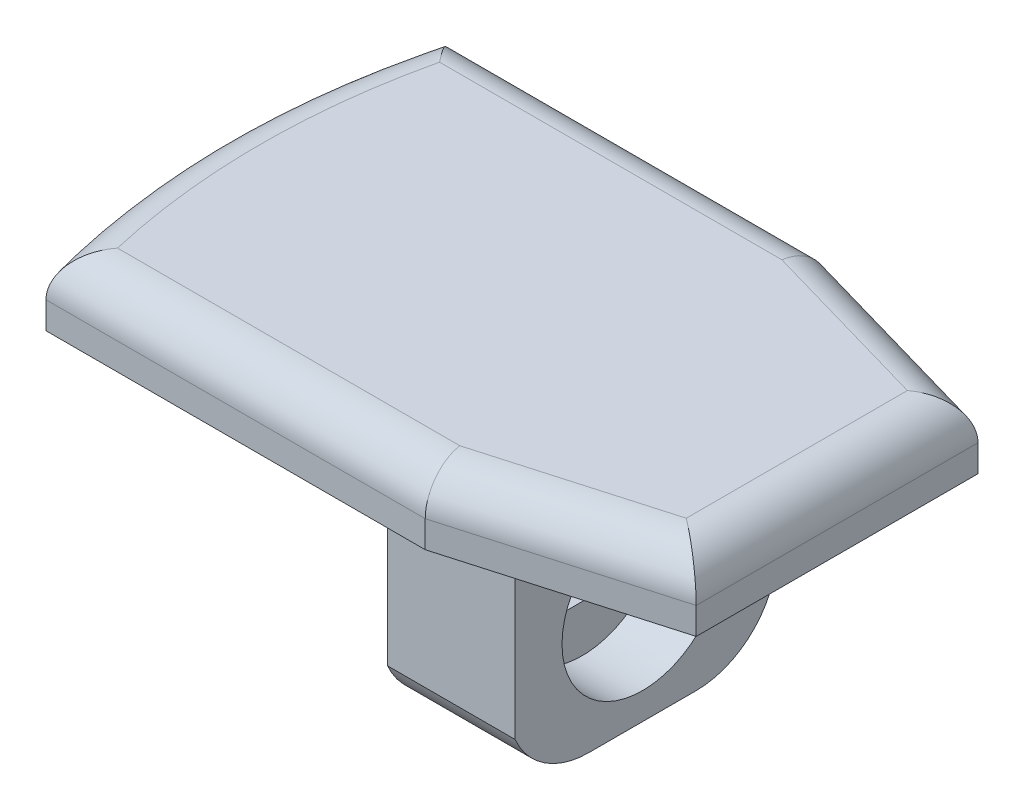
from build123d import *

# Parameters (mm, degrees)
BOSS_EXTRUDE1_DEPTH      = 2.5
BOSS_EXTRUDE2_DEPTH      = 1.5
BOSS_EXTRUDE2_DEPTH_BACK = 1.5
FILLET1_R                = 1.5
SKETCH5_W                = 5
SKETCH5_H                = 10
BOSS_EXTRUDE3_DEPTH      = 7.5
SKETCH6_R                = 3
CUT_EXTRUDE1_DEPTH       = 2.5
CUT_EXTRUDE2_DEPTH       = 2.5
FILLET2_R                = 3
CUT_EXTRUDE3_DEPTH       = 10


with BuildPart() as part:
    # Sketch1 → Boss-Extrude1 (new body)
    with BuildSketch(Plane(origin=(0, 0, 0), x_dir=(1, 0, 0), z_dir=(0, 1, 0))):
        with BuildLine():
            Line((-20.209371097, 50.622586501), (-32.257467167, 50.622586501))
            ThreePointArc((-32.257467167, 50.622586501), (-33.362688598, 43.122586501), (-32.257467167, 35.622586501))
            Line((-32.257467167, 35.622586501), (-20.209371097, 35.622586501))
            Line((-20.209371097, 35.622586501), (-12.362688598, 37.872586501))
            Line((-12.362688598, 37.872586501), (-12.362688598, 48.372586501))
            Line((-12.362688598, 48.372586501), (-20.209371097, 50.622586501))
        make_face()
        with BuildLine():
            Line((-32.257467167, 50.622586501), (-34.339530518, 50.622586501))
            ThreePointArc((-34.339530518, 50.622586501), (-35.362688598, 43.122586501), (-34.339530518, 35.622586501))
            Line((-34.339530518, 35.622586501), (-32.257467167, 35.622586501))
            ThreePointArc((-32.257467167, 35.622586501), (-33.362688598, 43.122586501), (-32.257467167, 50.622586501))
        make_face()
    extrude(amount=BOSS_EXTRUDE1_DEPTH)

    # Sketch4 → Boss-Extrude2 (add, two sides)
    with BuildSketch(Plane.XZ) as boss_extrude2_sk:
        with BuildLine():
            Line((-19.362688598, -38.122586501), (-32.877390242, -38.122586501))
            ThreePointArc((-32.877390242, -38.122586501), (-33.362688598, -43.122586501), (-32.877390242, -48.122586501))
            Line((-32.877390242, -48.122586501), (-19.362688598, -48.122586501))
            Line((-19.362688598, -48.122586501), (-19.362688598, -38.122586501))
        make_face()
    extrude(amount=BOSS_EXTRUDE2_DEPTH)
    extrude(boss_extrude2_sk.sketch, amount=-BOSS_EXTRUDE2_DEPTH_BACK)

    # Fillet1
    fillet1_edges = [part.edges().sort_by_distance(p)[0] for p in [
        (-27.274450808, 2.5, -35.622586501),
        (-16.286029847, 2.5, -36.747586501),
        (-12.362688598, 2.5, -43.122586501),
        (-16.286029847, 2.5, -49.497586501),
        (-27.274450808, 2.5, -50.622586501),
        (-35.362688598, 2.5, -43.122586501),
    ]]
    fillet(fillet1_edges, radius=FILLET1_R)

    # Sketch5 → Boss-Extrude3 (add)
    with BuildSketch(Plane.XZ.offset(1.5)):
        with Locations((-21.862688598, -43.122586501)):
            Rectangle(SKETCH5_W, SKETCH5_H)
    extrude(amount=BOSS_EXTRUDE3_DEPTH)

    # Sketch6 → Cut-Extrude1 (cut)
    with BuildSketch(Plane(origin=(-19.362688598, 0, 0), x_dir=(0, 0, -1), z_dir=(1, 0, 0))):
        with Locations((43.122586501, -5)):
            Circle(SKETCH6_R)
    extrude(amount=-CUT_EXTRUDE1_DEPTH, mode=Mode.SUBTRACT)

    # Sketch7 → Cut-Extrude2 (cut)
    with BuildSketch(Plane(origin=(-21.862688598, 0, 0), x_dir=(0, 0, -1), z_dir=(1, 0, 0))):
        with BuildLine():
            Line((45.84976453, -3.75), (40.395408473, -3.75))
            ThreePointArc((40.395408473, -3.75), (40.122586501, -5), (40.395408473, -6.25))
            Line((40.395408473, -6.25), (45.84976453, -6.25))
            ThreePointArc((45.84976453, -6.25), (46.053587532, -5.639713183), (46.122586501, -5))
            ThreePointArc((46.122586501, -5), (46.053587532, -4.360286817), (45.84976453, -3.75))
        make_face()
    extrude(amount=-CUT_EXTRUDE2_DEPTH, mode=Mode.SUBTRACT)

    # Fillet2
    fillet2_edges = [part.edges().sort_by_distance(p)[0] for p in [
        (-21.862688598, -9, -38.122586501),
        (-21.862688598, -9, -48.122586501),
    ]]
    fillet(fillet2_edges, radius=FILLET2_R)

    # Sketch8 → Cut-Extrude3 (cut)
    with BuildSketch(Plane.XZ):
        with BuildLine():
            Line((-19.362688598, -48.122586501), (-19.362688598, -38.122586501))
            Line((-19.362688598, -38.122586501), (-32.877390242, -38.122586501))
            ThreePointArc((-32.877390242, -38.122586501), (-33.362688598, -43.122586501), (-32.877390242, -48.122586501))
            Line((-32.877390242, -48.122586501), (-19.362688598, -48.122586501))
        make_face()
        with BuildLine():
            Line((-19.612688598, -47.872586501), (-19.612688598, -38.372586501))
            Line((-19.612688598, -38.372586501), (-32.670790068, -38.372586501))
            ThreePointArc((-32.670790068, -38.372586501), (-33.112688598, -43.122586501), (-32.670790068, -47.872586501))
            Line((-32.670790068, -47.872586501), (-19.612688598, -47.872586501))
        make_face(mode=Mode.SUBTRACT)
    extrude(amount=CUT_EXTRUDE3_DEPTH, mode=Mode.SUBTRACT)


solid = part.part
